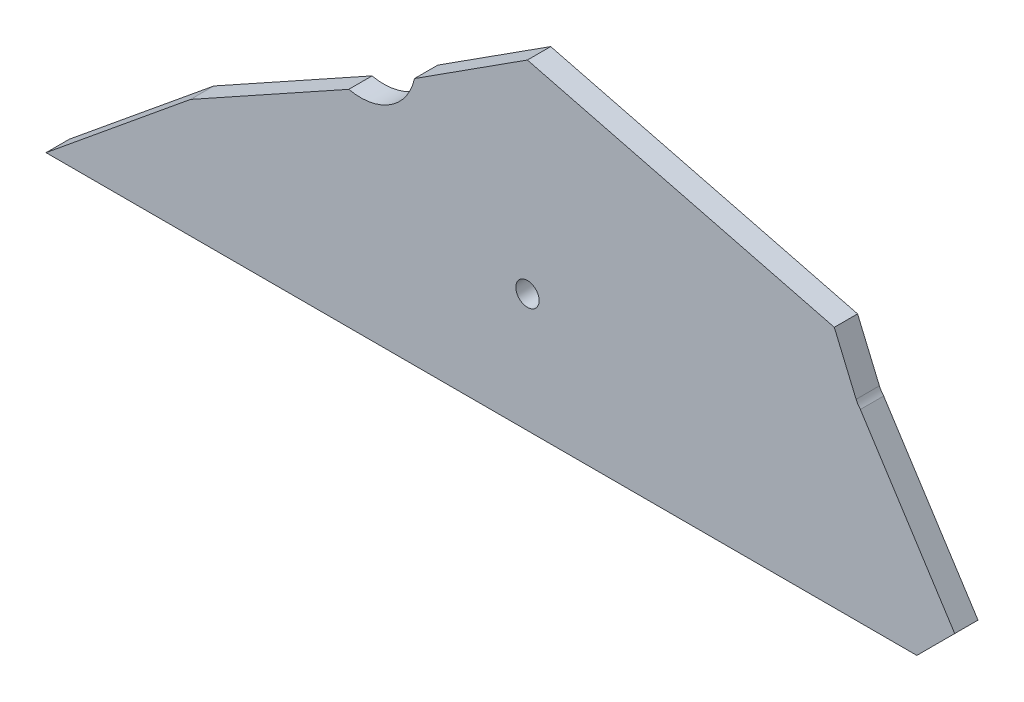
from build123d import *

# Parameters (mm, degrees)
BOSS_EXTRUDE1_DEPTH = 10
SKETCH2_R           = 5
CUT_EXTRUDE1_DEPTH  = 10


with BuildPart() as part:
    # Sketch1 → Boss-Extrude1 (new body)
    with BuildSketch(Plane.XY):
        with BuildLine():
            Line((-201.501450472, -50.838763567), (172.498549528, -50.838763567))
            Line((172.498549528, -50.838763567), (188.762005495, -34.5753076))
            Line((188.762005495, -34.5753076), (148.240026218, 28.535461651))
            ThreePointArc((148.240026218, 28.535461651), (147.2053445, 29.880442481), (146.412969402, 31.381002841))
            Line((146.412969402, 31.381002841), (137.047280897, 53.478149236))
            Line((137.047280897, 53.478149236), (5.239743471, 86.985955455))
            Line((5.239743471, 86.985955455), (-43.250387022, 55.851553414))
            ThreePointArc((-43.250387022, 55.851553414), (-53.613723576, 40.938672068), (-71.486708656, 37.721658093))
            Line((-71.486708656, 37.721658093), (-139.427338947, 0))
            Line((-139.427338947, 0), (-201.501450472, -50.838763567))
        make_face()
    extrude(amount=BOSS_EXTRUDE1_DEPTH)

    # Sketch2 → Cut-Extrude1 (cut)
    with BuildSketch(Plane.XY.offset(10)):
        with Locations((5.274158071, 0)):
            Circle(SKETCH2_R)
    extrude(amount=-CUT_EXTRUDE1_DEPTH, mode=Mode.SUBTRACT)


solid = part.part
